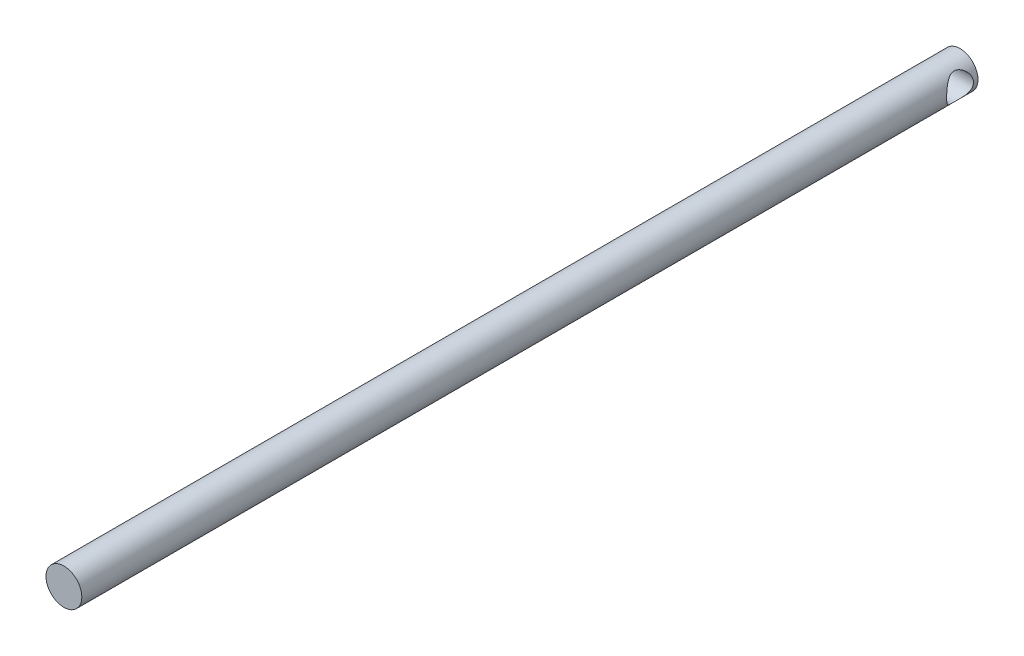
from build123d import *

# Parameters (mm, degrees)
SKETCH1_R               = 10
BOSS_EXTRUDE1_DEPTH     = 500
SKETCH2_R               = 7.5
CUT_EXTRUDE1_DEPTH      = 11
CUT_EXTRUDE1_DEPTH_BACK = 11


with BuildPart() as part:
    # Sketch1 → Boss-Extrude1 (new body)
    with BuildSketch(Plane.XY):
        Circle(SKETCH1_R)
    extrude(amount=BOSS_EXTRUDE1_DEPTH)

    # Sketch2 → Cut-Extrude1 (cut, two sides)
    with BuildSketch(Plane(origin=(0, 0, 0), x_dir=(0, 0, -1), z_dir=(1, 0, 0))) as cut_extrude1_sk:
        with Locations((-10, 0)):
            Circle(SKETCH2_R)
    extrude(amount=CUT_EXTRUDE1_DEPTH, mode=Mode.SUBTRACT)
    extrude(cut_extrude1_sk.sketch, amount=-CUT_EXTRUDE1_DEPTH_BACK, mode=Mode.SUBTRACT)


solid = part.part
